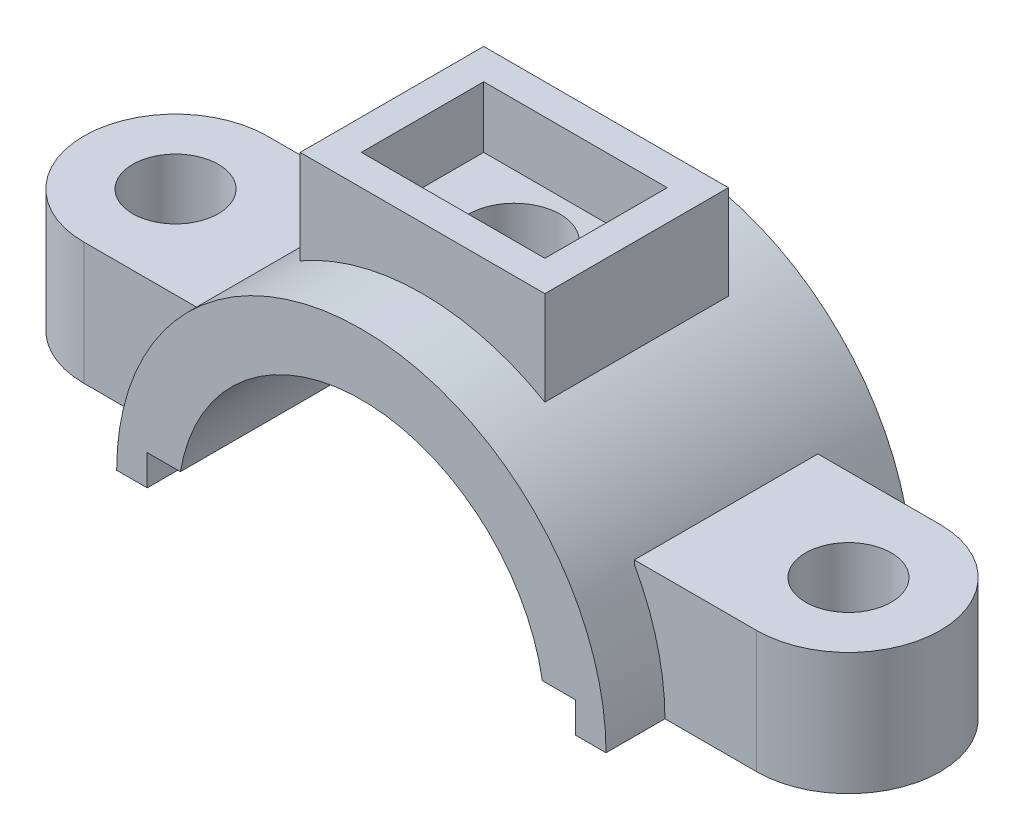
from build123d import *

# Parameters (mm, degrees)
BOSS_EXTRUDE1_DEPTH = 25
BOSS_EXTRUDE3_DEPTH = 20
SKETCH3_R           = 7
CUT_EXTRUDE1_DEPTH  = 20
SKETCH4_R           = 7
CUT_EXTRUDE2_DEPTH  = 20
BOSS_EXTRUDE4_REACH = 52
SKETCH5_W           = 40
SKETCH5_H           = 30
SKETCH6_W           = 30
SKETCH6_H           = 20
CUT_EXTRUDE3_DEPTH  = 10
CUT_EXTRUDE4_REACH  = 42
SKETCH7_R           = 7.5


with BuildPart() as part:
    # Sketch1 → Boss-Extrude1 (new body, symmetric)
    with BuildSketch(Plane.XY):
        with BuildLine():
            Line((-40, 0), (-35, 0))
            Line((-35, 0), (-35, 5))
            Line((-35, 5), (-29.580398915, 5))
            ThreePointArc((-29.580398915, 5), (0, 30), (29.580398915, 5))
            Line((29.580398915, 5), (35, 5))
            Line((35, 5), (35, 0))
            Line((35, 0), (40, 0))
            ThreePointArc((40, 0), (0, 40), (-40, 0))
        make_face()
    extrude(amount=BOSS_EXTRUDE1_DEPTH, both=True)

    # Sketch2 → Boss-Extrude3 (add)
    with BuildSketch(Plane(origin=(0, 0, 0), x_dir=(1, 0, 0), z_dir=(0, 1, 0))):
        with BuildLine():
            Line((35, 14.624040257), (35, -15.375959743))
            Line((35, -15.375959743), (55, -15.375959743))
            ThreePointArc((55, -15.375959743), (70, -0.375959743), (55, 14.624040257))
            Line((55, 14.624040257), (35, 14.624040257))
        make_face()
        with BuildLine():
            Line((-55, -15.375959743), (-35, -15.375959743))
            Line((-35, -15.375959743), (-35, 14.624040257))
            Line((-35, 14.624040257), (-55, 14.624040257))
            ThreePointArc((-55, 14.624040257), (-70, -0.375959743), (-55, -15.375959743))
        make_face()
    extrude(amount=BOSS_EXTRUDE3_DEPTH)

    # Sketch3 → Cut-Extrude1 (cut)
    with BuildSketch(Plane(origin=(0, 20, 0), x_dir=(1, 0, 0), z_dir=(0, 1, 0))):
        with Locations((55, -0.375959743)):
            Circle(SKETCH3_R)
    extrude(amount=-CUT_EXTRUDE1_DEPTH, mode=Mode.SUBTRACT)

    # Sketch4 → Cut-Extrude2 (cut)
    with BuildSketch(Plane(origin=(0, 20, 0), x_dir=(1, 0, 0), z_dir=(0, 1, 0))):
        with Locations((-55, -0.375959743)):
            Circle(SKETCH4_R)
    extrude(amount=-CUT_EXTRUDE2_DEPTH, mode=Mode.SUBTRACT)

    # Sketch5 → Boss-Extrude4 (add, up to next)
    with BuildSketch(Plane(origin=(0, 50, 0), x_dir=(1, 0, 0), z_dir=(0, 1, 0)), mode=Mode.PRIVATE) as boss_extrude4_sk1:
        Rectangle(SKETCH5_W, SKETCH5_H)
    boss_extrude4_tool1 = extrude(boss_extrude4_sk1.sketch, amount=-BOSS_EXTRUDE4_REACH, mode=Mode.PRIVATE) - part.part
    add(boss_extrude4_tool1.solids().sort_by_distance((0, 50, 0))[0])

    # Sketch6 → Cut-Extrude3 (cut)
    with BuildSketch(Plane(origin=(0, 50, 0), x_dir=(1, 0, 0), z_dir=(0, 1, 0))):
        Rectangle(SKETCH6_W, SKETCH6_H)
    extrude(amount=-CUT_EXTRUDE3_DEPTH, mode=Mode.SUBTRACT)

    # Sketch7 → Cut-Extrude4 (cut, up to next)
    with BuildSketch(Plane(origin=(0, 40, 0), x_dir=(1, 0, 0), z_dir=(0, 1, 0)), mode=Mode.PRIVATE) as cut_extrude4_sk1:
        Circle(SKETCH7_R)
    cut_extrude4_tool1 = extrude(cut_extrude4_sk1.sketch, amount=-CUT_EXTRUDE4_REACH, mode=Mode.PRIVATE) & part.part
    add(cut_extrude4_tool1.solids().sort_by_distance((0, 40, 0))[0], mode=Mode.SUBTRACT)


solid = part.part
